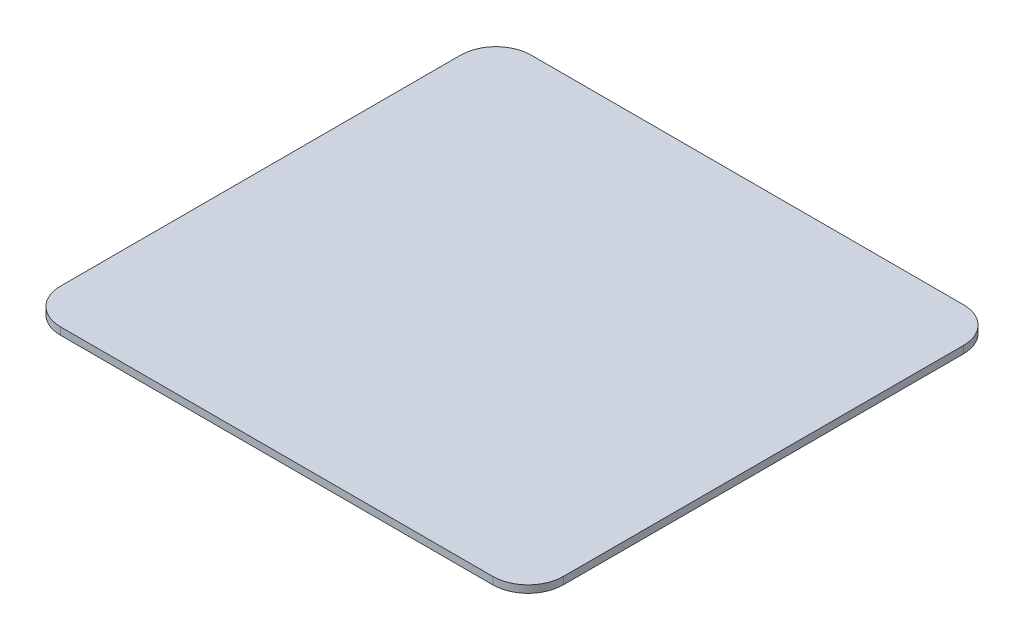
from build123d import *

# Parameters (mm, degrees)
SKETCH1_W           = 108.712
SKETCH1_H           = 101.7524
BOSS_EXTRUDE1_DEPTH = 1.5875
FILLET1_R           = 7.62


with BuildPart() as part:
    # Sketch1 → Boss-Extrude1 (new body)
    with BuildSketch(Plane(origin=(0, 0, 0), x_dir=(1, 0, 0), z_dir=(0, 1, 0))):
        Rectangle(SKETCH1_W, SKETCH1_H)
    extrude(amount=-BOSS_EXTRUDE1_DEPTH)

    # Fillet1
    fillet1_edges = [part.edges().sort_by_distance(p)[0] for p in [
        (-54.356, -0.79375, -50.8762),
        (54.356, -0.79375, -50.8762),
        (54.356, -0.79375, 50.8762),
        (-54.356, -0.79375, 50.8762),
    ]]
    fillet(fillet1_edges, radius=FILLET1_R)


solid = part.part
